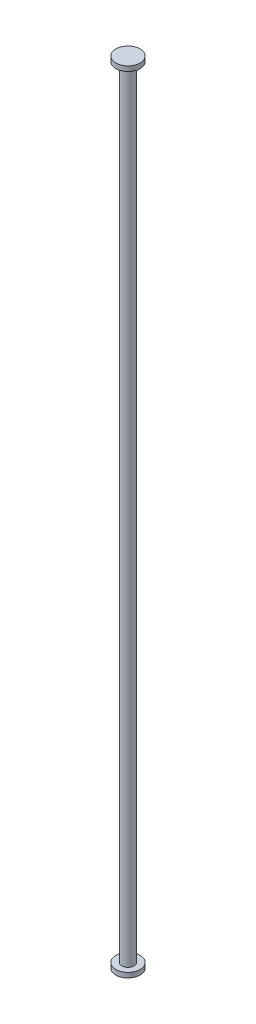
from build123d import *

# Parameters (mm, degrees)
SKETCH1_R           = 2.5
BOSS_EXTRUDE1_DEPTH = 320
SKETCH2_R           = 5
BOSS_EXTRUDE2_DEPTH = 2
SKETCH3_R           = 5
BOSS_EXTRUDE3_DEPTH = 2


with BuildPart() as part:
    # Sketch1 → Boss-Extrude1 (new body)
    with BuildSketch(Plane(origin=(0, 0, 0), x_dir=(1, 0, 0), z_dir=(0, 1, 0))):
        Circle(SKETCH1_R)
    extrude(amount=BOSS_EXTRUDE1_DEPTH)

    # Sketch2 → Boss-Extrude2 (add)
    with BuildSketch(Plane.XZ):
        Circle(SKETCH2_R)
    extrude(amount=BOSS_EXTRUDE2_DEPTH)

    # Sketch3 → Boss-Extrude3 (add)
    with BuildSketch(Plane(origin=(0, 320, 0), x_dir=(1, 0, 0), z_dir=(0, 1, 0))):
        Circle(SKETCH3_R)
    extrude(amount=BOSS_EXTRUDE3_DEPTH)


solid = part.part
